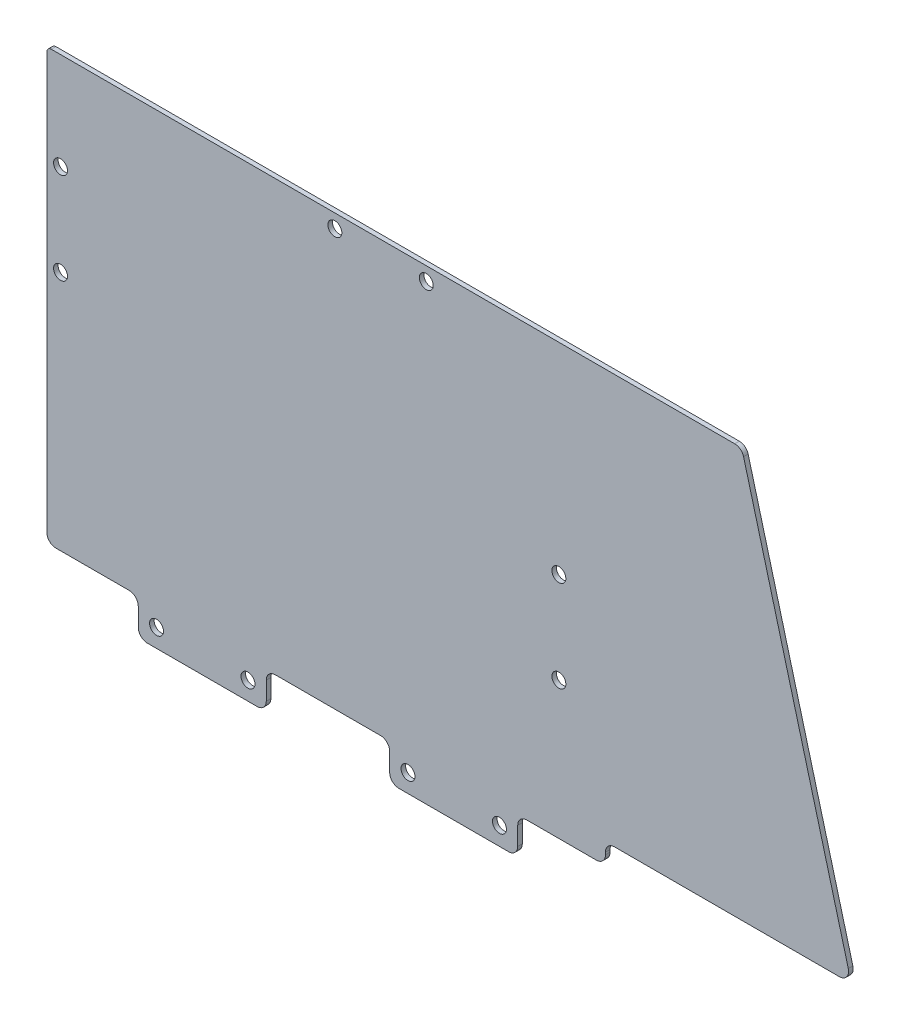
from build123d import *

# Parameters (mm, degrees)
SKETCH_1_W          = 28
SKETCH_1_H          = 8
SKETCH_1_R          = 1.525
EXTRUDE_1_DEPTH     = 1
FILLET_1_R          = 2
SKETCH_3_R          = 1.525
CUT_EXTRUDE_1_DEPTH = 10
CUT_EXTRUDE_2_DEPTH = 10
SKETCH_5_R          = 1.525
CUT_EXTRUDE_3_DEPTH = 10
FILLET_3_R          = 2
SKETCH_8_R          = 1.525
CUT_EXTRUDE_5_DEPTH = 5
SKETCH_9_W          = 29
SKETCH_9_H          = 22
CUT_EXTRUDE_6_DEPTH = 11
FILLET_4_R          = 1
EXTRUDE_2_DEPTH     = 1
SKETCH_12_W         = 55
SKETCH_12_H         = 4.5
CUT_EXTRUDE_7_DEPTH = 10
FILLET_5_R          = 2
SKETCH_13_W         = 32
SKETCH_13_H         = 8
CUT_EXTRUDE_8_DEPTH = 10
SKETCH_14_W         = 28
SKETCH_14_H         = 8
SKETCH_14_R         = 1.525
EXTRUDE_3_DEPTH     = 1
FILLET_6_R          = 2


with BuildPart() as part:
    # 草图1 → 凸台-拉伸1 (new body)
    with BuildSketch(Plane.XY):
        Polygon((-4, 4), (24, 4), (67, 4), (67, 120), (-51, 120), (-51, 4), align=None)
        with Locations((10, 0)):
            Rectangle(SKETCH_1_W, SKETCH_1_H)
        with Locations((20, 0)):
            Circle(SKETCH_1_R, mode=Mode.SUBTRACT)
        Circle(SKETCH_1_R, mode=Mode.SUBTRACT)
    extrude(amount=EXTRUDE_1_DEPTH)

    # 圆角1
    fillet_1_edges = [part.edges().sort_by_distance(p)[0] for p in [
        (67, 4, 0.5),
        (24, 4, 0.5),
        (24, -4, 0.5),
        (-4, -4, 0.5),
        (-4, 4, 0.5),
        (-51, 4, 0.5),
        (-51, 120, 0.5),
        (67, 120, 0.5),
    ]]
    fillet(fillet_1_edges, radius=FILLET_1_R)

    # 草图3 → 切除-拉伸1 (cut)
    with BuildSketch(Plane.XY.offset(1)):
        with Locations((-48, 76.75)):
            Circle(SKETCH_3_R)
        with Locations((-48, 56.75)):
            Circle(SKETCH_3_R)
    extrude(amount=-CUT_EXTRUDE_1_DEPTH, mode=Mode.SUBTRACT)

    # 草图4 → 切除-拉伸2 (cut)
    with BuildSketch(Plane.XY.offset(1)):
        with BuildLine():
            Line((65, 120), (-24, 120))
            Line((-24, 120), (-24, 98))
            Line((-24, 98), (67, 98))
            Line((67, 98), (67, 118))
            ThreePointArc((67, 118), (66.414213562, 119.414213562), (65, 120))
        make_face()
    extrude(amount=-CUT_EXTRUDE_2_DEPTH, mode=Mode.SUBTRACT)

    # 草图5 → 切除-拉伸3 (cut)
    with BuildSketch(Plane.XY.offset(1)):
        with Locations((61, 34)):
            Circle(SKETCH_5_R)
        with Locations((61, 54)):
            Circle(SKETCH_5_R)
    extrude(amount=-CUT_EXTRUDE_3_DEPTH, mode=Mode.SUBTRACT)

    # 圆角3
    fillet_3_edges = [part.edges().sort_by_distance(p)[0] for p in [
        (-24, 98, 0.5),
        (67, 98, 0.5),
        (-24, 120, 0.5),
    ]]
    fillet(fillet_3_edges, radius=FILLET_3_R)

    # 草图8 → 切除-拉伸5 (cut, symmetric)
    with BuildSketch(Plane.XY.offset(1)):
        with Locations((12, 95)):
            Circle(SKETCH_8_R)
        with Locations((32, 95)):
            Circle(SKETCH_8_R)
    extrude(amount=CUT_EXTRUDE_5_DEPTH, both=True, mode=Mode.SUBTRACT)

    # 草图9 → 切除-拉伸6 (cut, symmetric)
    with BuildSketch(Plane.XY.offset(1)):
        with Locations((-36.5, 109)):
            Rectangle(SKETCH_9_W, SKETCH_9_H)
    extrude(amount=CUT_EXTRUDE_6_DEPTH, both=True, mode=Mode.SUBTRACT)

    # 圆角4
    fillet_4_edges = [part.edges().sort_by_distance(p)[0] for p in [
        (-51, 98, 0.5),
    ]]
    fillet(fillet_4_edges, radius=FILLET_4_R)

    # 草图11 → 凸台-拉伸2 (add)
    with BuildSketch(Plane(origin=(0, 0, 0), x_dir=(-1, 0, 0), z_dir=(0, 0, -1))):
        with BuildLine():
            ThreePointArc((-67, 96), (-66.414213562, 97.414213562), (-65, 98))
            Line((-65, 98), (-101, 98))
            Line((-101, 98), (-126.187224089, 4))
            Line((-126.187224089, 4), (-65, 4))
            ThreePointArc((-65, 4), (-66.414213562, 4.585786438), (-67, 6))
            Line((-67, 6), (-67, 96))
        make_face()
    extrude(amount=-EXTRUDE_2_DEPTH)

    # 草图12 → 切除-拉伸7 (cut)
    with BuildSketch(Plane.XY.offset(1)):
        with Locations((98.687224089, 6.25)):
            Rectangle(SKETCH_12_W, SKETCH_12_H)
    extrude(amount=-CUT_EXTRUDE_7_DEPTH, mode=Mode.SUBTRACT)

    # 圆角5
    fillet_5_edges = [part.edges().sort_by_distance(p)[0] for p in [
        (101, 98, 0.5),
        (124.981452723, 8.5, 0.5),
        (71.187224089, 4, 0.5),
        (71.187224089, 8.5, 0.5),
    ]]
    fillet(fillet_5_edges, radius=FILLET_5_R)

    # 草图13 → 切除-拉伸8 (cut)
    with BuildSketch(Plane.XY.offset(1)):
        with Locations((10, 0)):
            Rectangle(SKETCH_13_W, SKETCH_13_H)
    extrude(amount=-CUT_EXTRUDE_8_DEPTH, mode=Mode.SUBTRACT)

    # 草图14 → 凸台-拉伸3 (add)
    with BuildSketch(Plane.XY.offset(1)):
        with Locations((-17, 0)):
            Rectangle(SKETCH_14_W, SKETCH_14_H)
        with Locations((-27, 0)):
            Circle(SKETCH_14_R, mode=Mode.SUBTRACT)
        with Locations((-7, 0)):
            Circle(SKETCH_14_R, mode=Mode.SUBTRACT)
        with Locations((38, 0)):
            Rectangle(SKETCH_14_W, SKETCH_14_H)
        with Locations((28, 0)):
            Circle(SKETCH_14_R, mode=Mode.SUBTRACT)
        with Locations((48, 0)):
            Circle(SKETCH_14_R, mode=Mode.SUBTRACT)
    extrude(amount=-EXTRUDE_3_DEPTH)

    # 圆角6
    fillet_6_edges = [part.edges().sort_by_distance(p)[0] for p in [
        (52, -4, 0.5),
        (52, 4, 0.5),
        (24, 4, 0.5),
        (24, -4, 0.5),
        (-3, -4, 0.5),
        (-3, 4, 0.5),
        (-31, 4, 0.5),
        (-31, -4, 0.5),
    ]]
    fillet(fillet_6_edges, radius=FILLET_6_R)


solid = part.part
